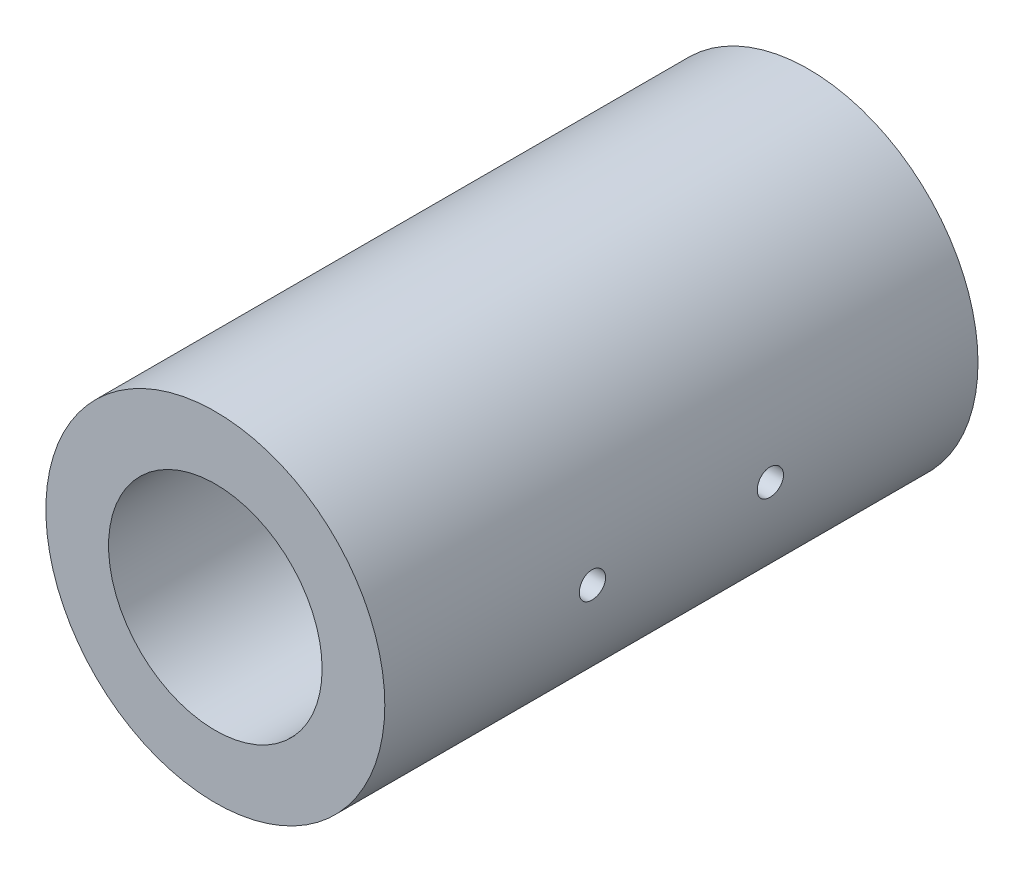
from build123d import *

# Parameters (mm, degrees)
SKETCH1_R               = 20
SKETCH1_R_2             = 12.6
BOSS_EXTRUDE1_DEPTH     = 70
SKETCH2_R               = 1.5
CUT_EXTRUDE1_DEPTH      = 10
SKETCH3_R               = 1.55
CUT_EXTRUDE2_DEPTH      = 21
CUT_EXTRUDE2_DEPTH_BACK = 21


with BuildPart() as part:
    # Sketch1 → Boss-Extrude1 (new body)
    with BuildSketch(Plane.XY):
        Circle(SKETCH1_R)
        Circle(SKETCH1_R_2, mode=Mode.SUBTRACT)
    extrude(amount=BOSS_EXTRUDE1_DEPTH)

    # Sketch2 → Cut-Extrude1 (cut)
    with BuildSketch(Plane(origin=(0, 0, 0), x_dir=(-1, 0, 0), z_dir=(0, 0, -1))):
        with Locations((0, 15.25)):
            Circle(SKETCH2_R)
        with Locations((15.25, 0)):
            Circle(SKETCH2_R)
        with Locations((0, -15.25)):
            Circle(SKETCH2_R)
        with Locations((-15.25, 0)):
            Circle(SKETCH2_R)
    extrude(amount=-CUT_EXTRUDE1_DEPTH, mode=Mode.SUBTRACT)

    # Sketch3 → Cut-Extrude2 (cut, two sides)
    with BuildSketch(Plane(origin=(0, 0, 0), x_dir=(0, 0, -1), z_dir=(1, 0, 0))) as cut_extrude2_sk:
        with Locations((-45.5, 0)):
            Circle(SKETCH3_R)
        with Locations((-24.5, 0)):
            Circle(SKETCH3_R)
    extrude(amount=CUT_EXTRUDE2_DEPTH, mode=Mode.SUBTRACT)
    extrude(cut_extrude2_sk.sketch, amount=-CUT_EXTRUDE2_DEPTH_BACK, mode=Mode.SUBTRACT)


solid = part.part
